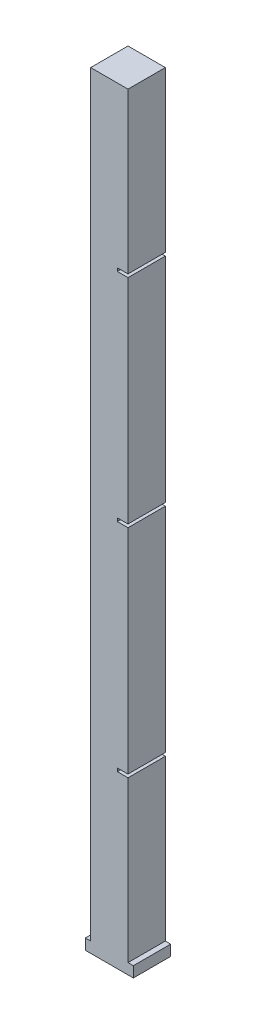
from build123d import *

# Parameters (mm, degrees)
BOSS_EXTRUDE1_DEPTH = 70


with BuildPart() as part:
    # Sketch2 → Boss-Extrude1 (new body)
    with BuildSketch(Plane.XY):
        Polygon((0, 0), (90, 0), (90, 20), (80, 20), (80, 320), (60, 320), (60, 326), (80, 326), (80, 726), (60, 726), (60, 732), (80, 732), (80, 1132), (60, 1132), (60, 1138), (80, 1138), (80, 1438), (10, 1438), (10, 20), (0, 20), align=None)
    extrude(amount=BOSS_EXTRUDE1_DEPTH)


solid = part.part
